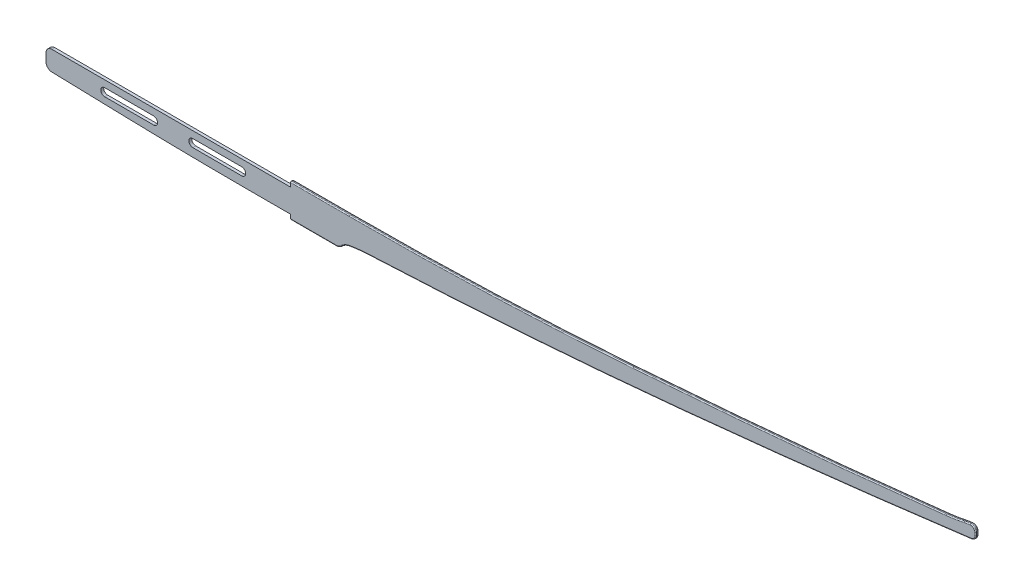
from build123d import *

# Parameters (mm, degrees)
EXTRUDE_1_DEPTH = 1.5
FILLET_1_R      = 1


with BuildPart() as part:
    # 草图1 → 凸台-拉伸1 (new body, symmetric)
    with BuildSketch(Plane.XY):
        with BuildLine():
            Line((0, 12), (-244, 12))
            ThreePointArc((-244, 12), (-248.242640687, 10.242640687), (-250, 6))
            Line((-250, 6), (-250, -2.163248404))
            ThreePointArc((-250, -2.163248404), (-248.300744725, -6.346978177), (-244.165468396, -8.160966321))
            Line((-244.165468396, -8.160966321), (-170, -10.207084742))
            ThreePointArc((-170, -10.207084742), (-105.006181524, -11.551749873), (-40, -12))
            Line((-40, -12), (0, -12))
            Line((0, -12), (0, -17))
            Line((0, -17), (46.26417673, -17))
            ThreePointArc((46.26417673, -17), (49.319600445, -16.393536767), (51.911773623, -14.666096481))
            ThreePointArc((51.911773623, -14.666096481), (55.632405886, -11.95502943), (60, -10.5))
            ThreePointArc((60, -10.5), (69.967296952, -9.127550858), (80, -8.368937164))
            ThreePointArc((80, -8.368937164), (240.153269938, 0.955681975), (400, 14.558669968))
            ThreePointArc((400, 14.558669968), (547.944123131, 30.255393679), (695.638352641, 48.151350585))
            ThreePointArc((695.638352641, 48.151350585), (698.754448242, 49.808295298), (700, 53.110433757))
            Line((700, 53.110433757), (700, 56.167376267))
            ThreePointArc((700, 56.167376267), (698.391164992, 59.841610881), (694.6, 61.151350585))
            ThreePointArc((694.6, 61.151350585), (691.284376207, 60.77672414), (688, 60.188014503))
            ThreePointArc((688, 60.188014503), (679.035528815, 58.505530478), (670, 57.25985189))
            ThreePointArc((670, 57.25985189), (510.149322959, 40.78604705), (350, 27.526350507))
            ThreePointArc((350, 27.526350507), (205.095489295, 19.632453853), (60, 17))
            Line((60, 17), (0, 17))
            Line((0, 17), (0, 12))
        make_face()
        with BuildLine():
            Line((-50, -3), (-100, -3))
            ThreePointArc((-100, -3), (-104, 1), (-100, 5))
            Line((-100, 5), (-50, 5))
            ThreePointArc((-50, 5), (-46, 1), (-50, -3))
        make_face(mode=Mode.SUBTRACT)
        with BuildLine():
            Line((-140, -3), (-190, -3))
            ThreePointArc((-190, -3), (-194, 1), (-190, 5))
            Line((-190, 5), (-140, 5))
            ThreePointArc((-140, 5), (-136, 1), (-140, -3))
        make_face(mode=Mode.SUBTRACT)
    extrude(amount=EXTRUDE_1_DEPTH, both=True)

    # 圆角1
    fillet_1_edges = [part.edges().sort_by_distance(p)[0] for p in [
        (30, 17, -1.5),
        (205.095489295, 19.632453853, -1.5),
        (510.149322959, 40.78604705, -1.5),
        (679.035528815, 58.505530478, -1.5),
        (691.284376207, 60.77672414, -1.5),
        (698.391164992, 59.841610881, -1.5),
        (700, 54.638905012, -1.5),
        (698.754448242, 49.808295298, -1.5),
        (547.944123131, 30.255393679, -1.5),
        (240.153269938, 0.955681975, -1.5),
        (69.967296952, -9.127550858, -1.5),
        (55.632405886, -11.95502943, -1.5),
        (49.319600445, -16.393536767, -1.5),
        (23.132088365, -17, -1.5),
        (23.132088365, -17, 1.5),
        (49.319600445, -16.393536767, 1.5),
        (55.632405886, -11.95502943, 1.5),
        (69.967296952, -9.127550858, 1.5),
        (240.153269938, 0.955681975, 1.5),
        (547.944123131, 30.255393679, 1.5),
        (698.754448242, 49.808295298, 1.5),
        (700, 54.638905012, 1.5),
        (698.391164992, 59.841610881, 1.5),
        (691.284376207, 60.77672414, 1.5),
        (679.035528815, 58.505530478, 1.5),
        (510.149322959, 40.78604705, 1.5),
        (205.095489295, 19.632453853, 1.5),
        (30, 17, 1.5),
    ]]
    fillet(fillet_1_edges, radius=FILLET_1_R)


solid = part.part
